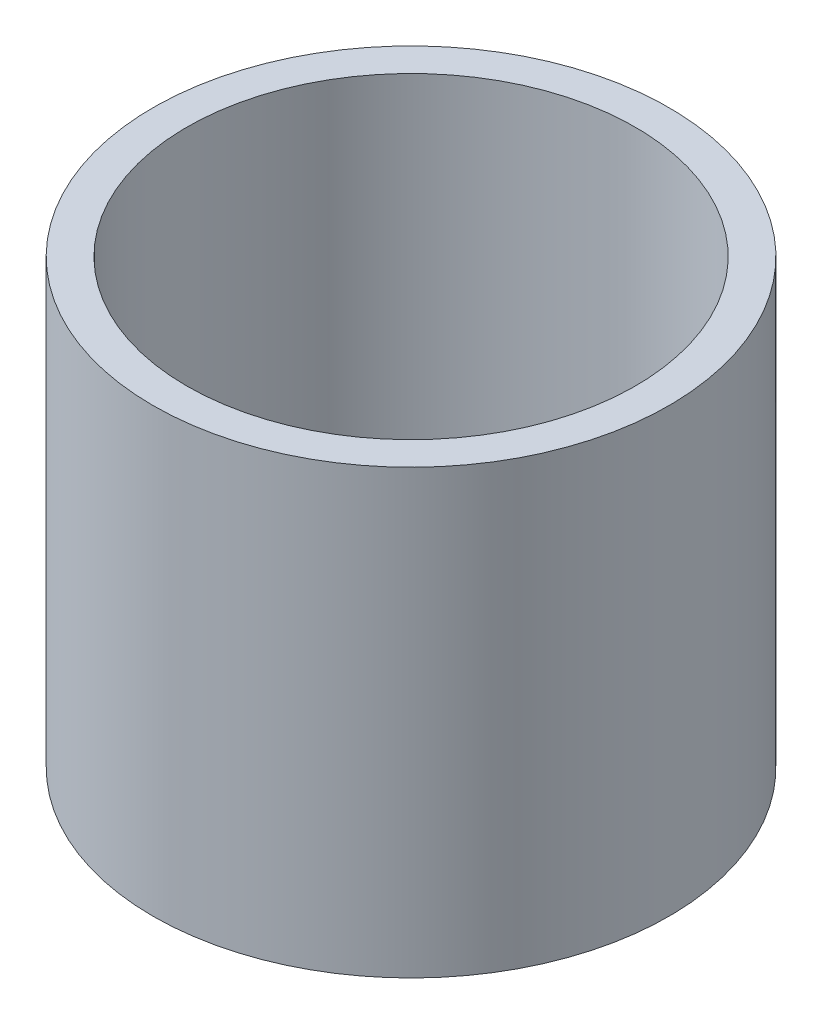
from build123d import *

# Parameters (mm, degrees)
SKETCH2_R           = 44.45
SKETCH2_R_2         = 38.6334
BOSS_EXTRUDE1_DEPTH = 76.2


with BuildPart() as part:
    # Sketch2 → Boss-Extrude1 (new body)
    with BuildSketch(Plane(origin=(0, 0, 0), x_dir=(1, 0, 0), z_dir=(0, 1, 0))):
        Circle(SKETCH2_R)
        Circle(SKETCH2_R_2, mode=Mode.SUBTRACT)
    extrude(amount=BOSS_EXTRUDE1_DEPTH)


solid = part.part
